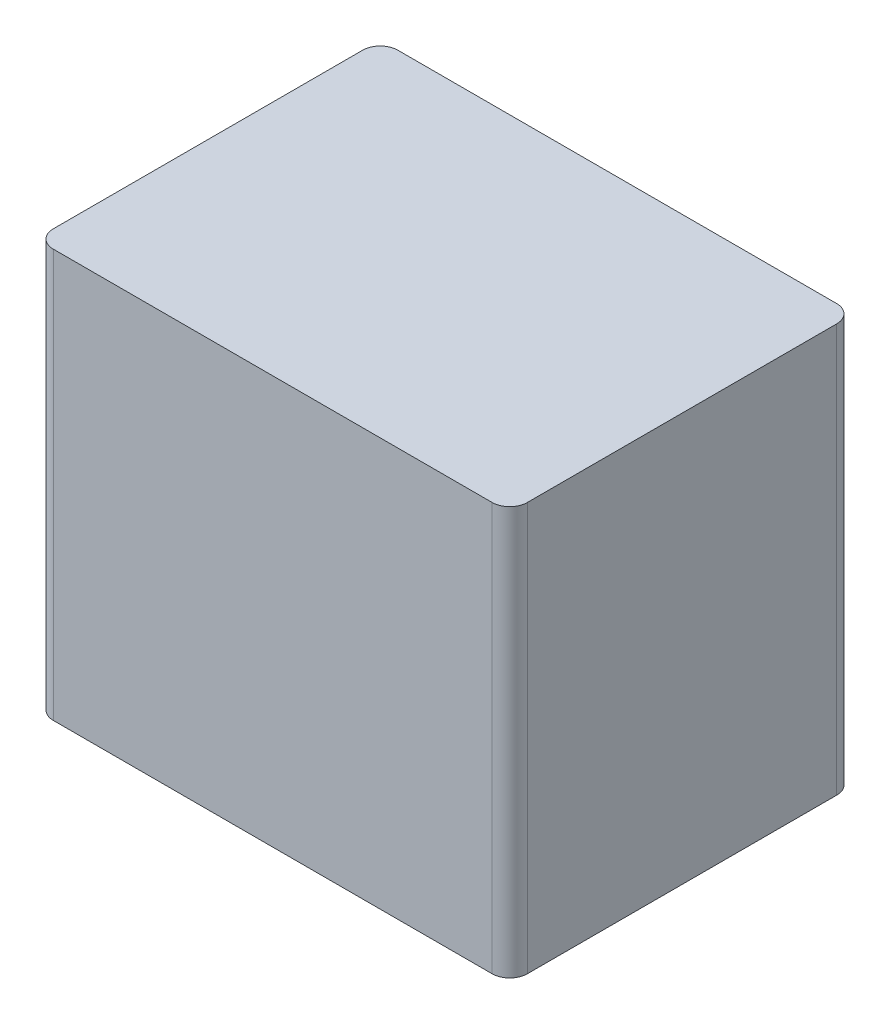
from build123d import *

# Parameters (mm, degrees)
SKETCH1_W           = 54
SKETCH1_H           = 39.25
BOSS_EXTRUDE1_DEPTH = 46.5
FILLET1_R           = 2
FILLET2_R           = 2


with BuildPart() as part:
    # Sketch1 → Boss-Extrude1 (new body)
    with BuildSketch(Plane(origin=(0, 0, 0), x_dir=(1, 0, 0), z_dir=(0, 1, 0))):
        with Locations((27, 19.625)):
            Rectangle(SKETCH1_W, SKETCH1_H)
    extrude(amount=BOSS_EXTRUDE1_DEPTH)

    # Fillet1
    fillet1_edges = [part.edges().sort_by_distance(p)[0] for p in [
        (0, 23.25, 0),
    ]]
    fillet(fillet1_edges, radius=FILLET1_R)

    # Fillet2
    fillet2_edges = [part.edges().sort_by_distance(p)[0] for p in [
        (0, 23.25, -39.25),
        (54, 23.25, -39.25),
        (54, 23.25, 0),
    ]]
    fillet(fillet2_edges, radius=FILLET2_R)


solid = part.part
